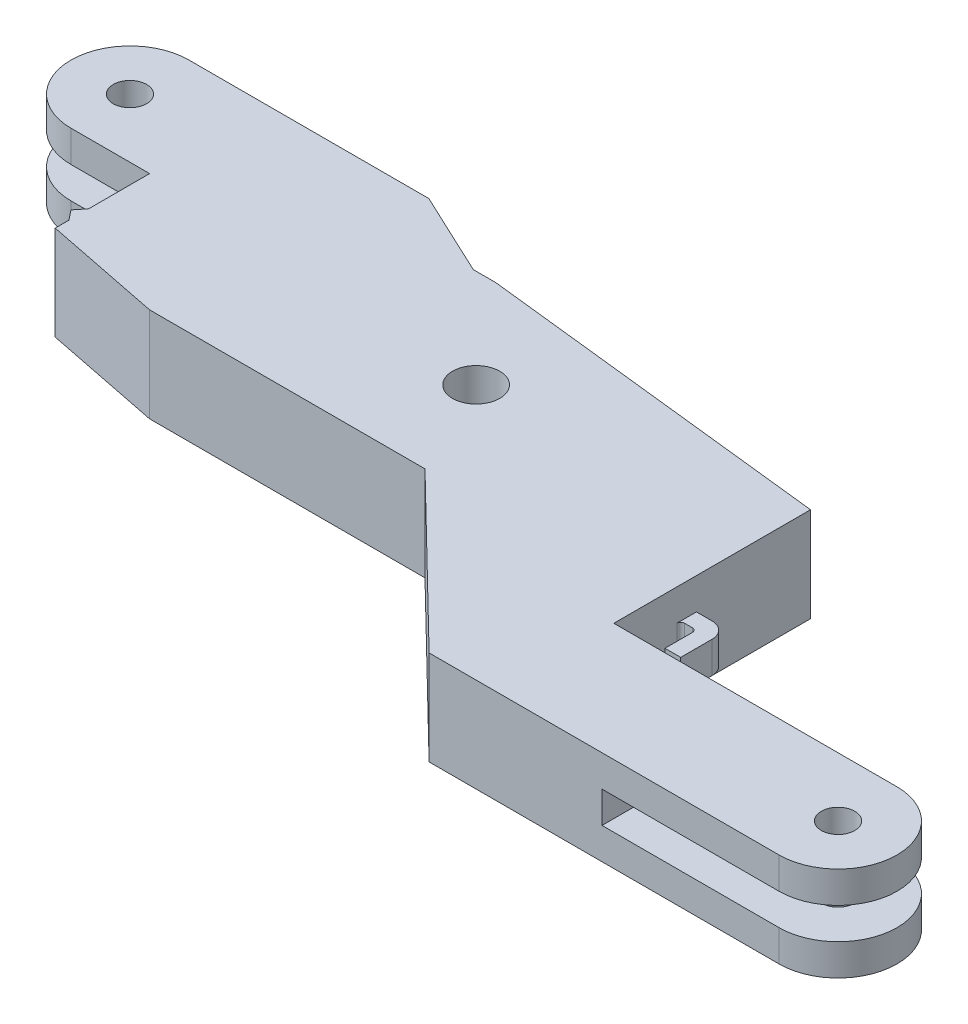
from build123d import *

# Parameters (mm, degrees)
SKETCH1_R           = 2.125
SKETCH1_R_2         = 3
BOSS_EXTRUDE1_DEPTH = 12
SKETCH2_W           = 40
SKETCH2_H           = 4
SLOT1_CUT_DEPTH     = 15
SKETCH3_W           = 30
SKETCH3_H           = 4
SLOT2_CUT_DEPTH     = 138.569073559
CUT_EXTRUDE3_DEPTH  = 140.665672232
SKETCH5_W           = 6
SKETCH5_H           = 4
BOSS_EXTRUDE2_DEPTH = 4
CUT_EXTRUDE4_DEPTH  = 4
SKETCH7_W           = 2.5
SKETCH7_H           = 12
BOSS_EXTRUDE3_DEPTH = 1
CUT_EXTRUDE5_DEPTH  = 140.665672232


with BuildPart() as part:
    # Sketch1 → Boss-Extrude1 (new body)
    with BuildSketch(Plane(origin=(0, 0, 0), x_dir=(1, 0, 0), z_dir=(0, 1, 0))):
        with BuildLine():
            Line((0, -7.5), (10, -7.5))
            Line((10, -7.5), (10, -22.5))
            Line((10, -22.5), (60, -22.5))
            Line((60, -22.5), (80.52220172, -42.5))
            Line((80.52220172, -42.5), (125, -42.5))
            ThreePointArc((125, -42.5), (132.5, -35), (125, -27.5))
            Line((125, -27.5), (89, -27.5))
            Line((89, -27.5), (89, 2.5))
            Line((89, 2.5), (41.141232585, 2.5))
            Line((41.141232585, 2.5), (30.480824737, 7.5))
            Line((30.480824737, 7.5), (0, 7.5))
            ThreePointArc((0, 7.5), (-7.5, 0), (0, -7.5))
        make_face()
        with Locations(Location((0, 0, 0), (0, 0, 270))):
            Circle(SKETCH1_R, mode=Mode.SUBTRACT)
        with Locations(Location((125, -35, 0), (0, 0, 270))):
            Circle(SKETCH1_R, mode=Mode.SUBTRACT)
        with Locations(Location((54, -10, 0), (0, 0, 270))):
            Circle(SKETCH1_R_2, mode=Mode.SUBTRACT)
    extrude(amount=BOSS_EXTRUDE1_DEPTH)

    # Sketch2 → Slot1 Cut (cut)
    with BuildSketch(Plane(origin=(0, 0, -7.5), x_dir=(-1, 0, 0), z_dir=(0, 0, -1))):
        with Locations((-12.5, 6)):
            Rectangle(SKETCH2_W, SKETCH2_H)
    extrude(amount=-SLOT1_CUT_DEPTH, mode=Mode.SUBTRACT)

    # Sketch3 → Slot2 Cut (cut, through all)
    with BuildSketch(Plane(origin=(0, 0, 27.5), x_dir=(-1, 0, 0), z_dir=(0, 0, -1))):
        with Locations((-117.5, 6)):
            Rectangle(SKETCH3_W, SKETCH3_H)
    extrude(amount=-SLOT2_CUT_DEPTH, mode=Mode.SUBTRACT)

    # Sketch4 → Cut-Extrude3 (cut, through all)
    with BuildSketch(Plane(origin=(0, 12, 0), x_dir=(1, 0, 0), z_dir=(0, 1, 0))):
        Polygon((10, -19.5), (10, -22.5), (25, -22.5), align=None)
        Polygon((44, 2.5), (89, 2.5), (89, -2.5), align=None)
    extrude(amount=-CUT_EXTRUDE3_DEPTH, mode=Mode.SUBTRACT)

    # Sketch5 → Boss-Extrude2 (add)
    with BuildSketch(Plane(origin=(89, 0, 0), x_dir=(0, 0, -1), z_dir=(1, 0, 0))):
        with Locations((-20, 6)):
            Rectangle(SKETCH5_W, SKETCH5_H)
    extrude(amount=BOSS_EXTRUDE2_DEPTH)

    # Sketch6 → Cut-Extrude4 (cut)
    with BuildSketch(Plane(origin=(0, 8, 0), x_dir=(1, 0, 0), z_dir=(0, 1, 0))):
        with BuildLine():
            Line((91, -23), (89, -23))
            Line((89, -23), (89, -19.5))
            ThreePointArc((89, -19.5), (89.146446609, -19.146446609), (89.5, -19))
            Line((89.5, -19), (90.5, -19))
            ThreePointArc((90.5, -19), (90.853553391, -19.146446609), (91, -19.5))
            Line((91, -19.5), (91, -23))
        make_face()
        with BuildLine():
            Line((91, -17), (93, -17))
            Line((93, -17), (93, -19))
            ThreePointArc((93, -19), (92.414213562, -17.585786438), (91, -17))
        make_face()
    extrude(amount=-CUT_EXTRUDE4_DEPTH, mode=Mode.SUBTRACT)

    # Sketch7 → Boss-Extrude3 (add)
    with BuildSketch(Plane.ZY.offset(-10)):
        with Locations((16.5, 6)):
            Rectangle(SKETCH7_W, SKETCH7_H)
    extrude(amount=BOSS_EXTRUDE3_DEPTH)

    # Sketch8 → Cut-Extrude5 (cut, through all)
    with BuildSketch(Plane(origin=(0, 12, 0), x_dir=(1, 0, 0), z_dir=(0, 1, 0))):
        Polygon((9, -16.5), (10, -15.25), (9, -15.25), align=None)
        Polygon((10, -17.75), (9, -16.5), (9, -17.75), align=None)
    extrude(amount=-CUT_EXTRUDE5_DEPTH, mode=Mode.SUBTRACT)


solid = part.part
